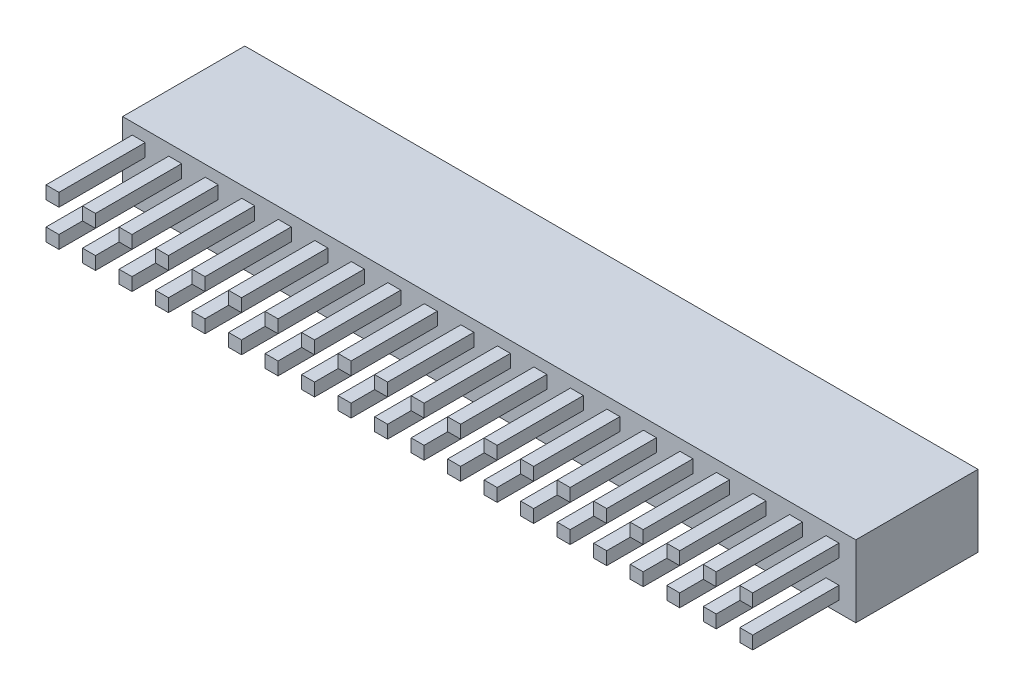
from build123d import *

# Parameters (mm, degrees)
SKETCH_1_W      = 51
SKETCH_1_H      = 5
EXTRUDE_1_DEPTH = 8.5
SKETCH_3_W      = 0.9
SKETCH_3_H      = 0.9
EXTRUDE_2_DEPTH = 6


with BuildPart() as part:
    # 草图1 → 凸台-拉伸1 (new body)
    with BuildSketch(Plane.XY):
        with Locations((-62.234353046, 55.774690545)):
            Rectangle(SKETCH_1_W, SKETCH_1_H)
    extrude(amount=EXTRUDE_1_DEPTH)

    # 草图3 → 凸台-拉伸2 (add)
    with BuildSketch(Plane.XY.offset(8.5)):
        with Locations((-84.074353046, 57.044690545)):
            Rectangle(SKETCH_3_W, SKETCH_3_H)
        with Locations((-86.614353046, 57.044690545)):
            Rectangle(SKETCH_3_W, SKETCH_3_H)
        with Locations((-81.534353046, 57.044690545)):
            Rectangle(SKETCH_3_W, SKETCH_3_H)
        with Locations((-78.994353046, 57.044690545)):
            Rectangle(SKETCH_3_W, SKETCH_3_H)
        with Locations((-76.454353046, 57.044690545)):
            Rectangle(SKETCH_3_W, SKETCH_3_H)
        with Locations((-73.914353046, 57.044690545)):
            Rectangle(SKETCH_3_W, SKETCH_3_H)
        with Locations((-71.374353046, 57.044690545)):
            Rectangle(SKETCH_3_W, SKETCH_3_H)
        with Locations((-68.834353046, 57.044690545)):
            Rectangle(SKETCH_3_W, SKETCH_3_H)
        with Locations((-66.294353046, 57.044690545)):
            Rectangle(SKETCH_3_W, SKETCH_3_H)
        with Locations((-63.754353046, 57.044690545)):
            Rectangle(SKETCH_3_W, SKETCH_3_H)
        with Locations((-61.214353046, 57.044690545)):
            Rectangle(SKETCH_3_W, SKETCH_3_H)
        with Locations((-58.674353046, 57.044690545)):
            Rectangle(SKETCH_3_W, SKETCH_3_H)
        with Locations((-56.134353046, 57.044690545)):
            Rectangle(SKETCH_3_W, SKETCH_3_H)
        with Locations((-53.594353046, 57.044690545)):
            Rectangle(SKETCH_3_W, SKETCH_3_H)
        with Locations((-51.054353046, 57.044690545)):
            Rectangle(SKETCH_3_W, SKETCH_3_H)
        with Locations((-48.514353046, 57.044690545)):
            Rectangle(SKETCH_3_W, SKETCH_3_H)
        with Locations((-45.974353046, 57.044690545)):
            Rectangle(SKETCH_3_W, SKETCH_3_H)
        with Locations((-43.434353046, 57.044690545)):
            Rectangle(SKETCH_3_W, SKETCH_3_H)
        with Locations((-40.894353046, 57.044690545)):
            Rectangle(SKETCH_3_W, SKETCH_3_H)
        with Locations((-38.354353046, 57.044690545)):
            Rectangle(SKETCH_3_W, SKETCH_3_H)
        with Locations((-84.074353046, 54.504690545)):
            Rectangle(SKETCH_3_W, SKETCH_3_H)
        with Locations((-81.534353046, 54.504690545)):
            Rectangle(SKETCH_3_W, SKETCH_3_H)
        with Locations((-78.994353046, 54.504690545)):
            Rectangle(SKETCH_3_W, SKETCH_3_H)
        with Locations((-76.454353046, 54.504690545)):
            Rectangle(SKETCH_3_W, SKETCH_3_H)
        with Locations((-73.914353046, 54.504690545)):
            Rectangle(SKETCH_3_W, SKETCH_3_H)
        with Locations((-71.374353046, 54.504690545)):
            Rectangle(SKETCH_3_W, SKETCH_3_H)
        with Locations((-68.834353046, 54.504690545)):
            Rectangle(SKETCH_3_W, SKETCH_3_H)
        with Locations((-66.294353046, 54.504690545)):
            Rectangle(SKETCH_3_W, SKETCH_3_H)
        with Locations((-63.754353046, 54.504690545)):
            Rectangle(SKETCH_3_W, SKETCH_3_H)
        with Locations((-61.214353046, 54.504690545)):
            Rectangle(SKETCH_3_W, SKETCH_3_H)
        with Locations((-58.674353046, 54.504690545)):
            Rectangle(SKETCH_3_W, SKETCH_3_H)
        with Locations((-56.134353046, 54.504690545)):
            Rectangle(SKETCH_3_W, SKETCH_3_H)
        with Locations((-53.594353046, 54.504690545)):
            Rectangle(SKETCH_3_W, SKETCH_3_H)
        with Locations((-51.054353046, 54.504690545)):
            Rectangle(SKETCH_3_W, SKETCH_3_H)
        with Locations((-48.514353046, 54.504690545)):
            Rectangle(SKETCH_3_W, SKETCH_3_H)
        with Locations((-45.974353046, 54.504690545)):
            Rectangle(SKETCH_3_W, SKETCH_3_H)
        with Locations((-43.434353046, 54.504690545)):
            Rectangle(SKETCH_3_W, SKETCH_3_H)
        with Locations((-40.894353046, 54.504690545)):
            Rectangle(SKETCH_3_W, SKETCH_3_H)
        with Locations((-38.354353046, 54.504690545)):
            Rectangle(SKETCH_3_W, SKETCH_3_H)
        with Locations((-86.614353046, 54.504690545)):
            Rectangle(SKETCH_3_W, SKETCH_3_H)
    extrude(amount=EXTRUDE_2_DEPTH)


solid = part.part
